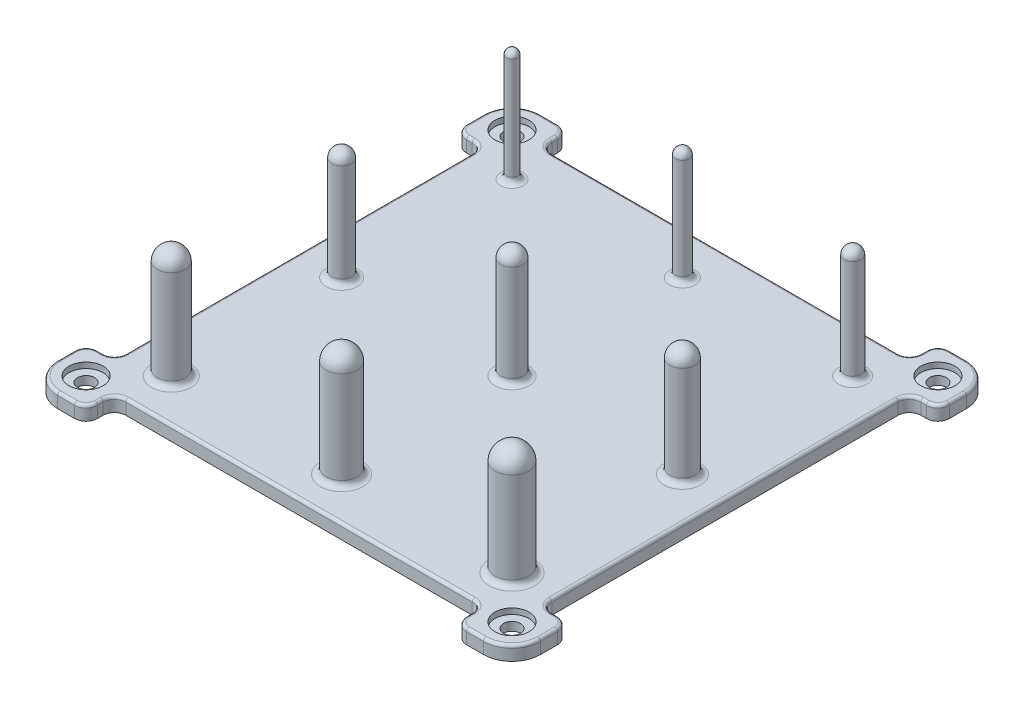
from build123d import *

# Parameters (mm, degrees)
BOSS_EXTRUDE1_DEPTH = 5
SKETCH3_R           = 6
CUT_EXTRUDE1_DEPTH  = 2
SKETCH9_R           = 3
CUT_EXTRUDE4_DEPTH  = 6
SKETCH10_R          = 2
SKETCH10_R_2        = 2.5
SKETCH10_R_3        = 3
SKETCH10_R_4        = 3.5
SKETCH10_R_5        = 4
SKETCH10_R_6        = 4.5
SKETCH10_R_7        = 5
SKETCH10_R_8        = 5.5
SKETCH10_R_9        = 6
BOSS_EXTRUDE6_DEPTH = 40
FILLET1_R           = 2
FILLET2_R           = 2.5
FILLET3_R           = 3
FILLET4_R           = 3.5
FILLET5_R           = 4
FILLET6_R           = 4.5
FILLET7_R           = 5
FILLET8_R           = 5.5
FILLET9_R           = 6
FILLET11_R          = 2
FILLET12_R          = 2
FILLET13_R          = 2
FILLET14_R          = 2
FILLET15_R          = 2
FILLET16_R          = 2
FILLET17_R          = 2
FILLET18_R          = 2
FILLET19_R          = 2
SKETCH12_OUTSIDE_W  = 220.918
SKETCH12_OUTSIDE_H  = 220.918
CUT_EXTRUDE5_DEPTH  = 40
FILLET20_R          = 1


with BuildPart() as part:
    # Sketch2 → Boss-Extrude1 (new body)
    with BuildSketch(Plane(origin=(0, 0, 0), x_dir=(1, 0, 0), z_dir=(0, 1, 0))):
        with BuildLine():
            Line((-78.251928021, 33.643958869), (71.748071979, 33.643958869))
            ThreePointArc((71.748071979, 33.643958869), (78.819139791, 30.715026681), (81.748071979, 23.643958869))
            Line((81.748071979, 23.643958869), (81.748071979, -126.356041131))
            ThreePointArc((81.748071979, -126.356041131), (78.819139791, -133.427108943), (71.748071979, -136.356041131))
            Line((71.748071979, -136.356041131), (-78.251928021, -136.356041131))
            ThreePointArc((-78.251928021, -136.356041131), (-85.322995832, -133.427108943), (-88.251928021, -126.356041131))
            Line((-88.251928021, -126.356041131), (-88.251928021, 23.643958869))
            ThreePointArc((-88.251928021, 23.643958869), (-85.322995832, 30.715026681), (-78.251928021, 33.643958869))
        make_face()
    extrude(amount=BOSS_EXTRUDE1_DEPTH)

    # Sketch3 → Cut-Extrude1 (cut)
    with BuildSketch(Plane(origin=(0, 5, 0), x_dir=(1, 0, 0), z_dir=(0, 1, 0))):
        with Locations((71.748071979, 23.643958869)):
            Circle(SKETCH3_R)
        with Locations((71.748071979, -126.356041131)):
            Circle(SKETCH3_R)
        with Locations((-78.251928021, 23.643958869)):
            Circle(SKETCH3_R)
        with Locations((-78.251928021, -126.356041131)):
            Circle(SKETCH3_R)
    extrude(amount=-CUT_EXTRUDE1_DEPTH, mode=Mode.SUBTRACT)

    # Sketch9 → Cut-Extrude4 (cut, through all)
    with BuildSketch(Plane(origin=(0, 5, 0), x_dir=(1, 0, 0), z_dir=(0, 1, 0))):
        with Locations((-78.251928021, 23.643958869)):
            Circle(SKETCH9_R)
        with Locations((71.748071979, 23.643958869)):
            Circle(SKETCH9_R)
        with Locations((71.748071979, -126.356041131)):
            Circle(SKETCH9_R)
        with Locations((-78.251928021, -126.356041131)):
            Circle(SKETCH9_R)
    extrude(amount=-CUT_EXTRUDE4_DEPTH, mode=Mode.SUBTRACT)

    # Sketch10 → Boss-Extrude6 (add)
    with BuildSketch(Plane(origin=(0, 5, 0), x_dir=(1, 0, 0), z_dir=(0, 1, 0))):
        with Locations((-63.251928021, 8.643958869)):
            Circle(SKETCH10_R)
        with Locations((-3.251928021, 8.643958869)):
            Circle(SKETCH10_R_2)
        with Locations((56.748071979, 8.643958869)):
            Circle(SKETCH10_R_3)
        with Locations((-63.251928021, -51.356041131)):
            Circle(SKETCH10_R_4)
        with Locations((-3.251928021, -51.356041131)):
            Circle(SKETCH10_R_5)
        with Locations((56.748071979, -51.356041131)):
            Circle(SKETCH10_R_6)
        with Locations((-63.251928021, -111.356041131)):
            Circle(SKETCH10_R_7)
        with Locations((-3.251928021, -111.356041131)):
            Circle(SKETCH10_R_8)
        with Locations((56.748071979, -111.356041131)):
            Circle(SKETCH10_R_9)
    extrude(amount=BOSS_EXTRUDE6_DEPTH)

    # Fillet1
    fillet1_edges = [part.edges().sort_by_distance(p)[0] for p in [
        (-65.251928021, 45, -8.643958869),
    ]]
    fillet(fillet1_edges, radius=FILLET1_R)

    # Fillet2
    fillet2_edges = [part.edges().sort_by_distance(p)[0] for p in [
        (-5.751928021, 45, -8.643958869),
    ]]
    fillet(fillet2_edges, radius=FILLET2_R)

    # Fillet3
    fillet3_edges = [part.edges().sort_by_distance(p)[0] for p in [
        (53.748071979, 45, -8.643958869),
    ]]
    fillet(fillet3_edges, radius=FILLET3_R)

    # Fillet4
    fillet4_edges = [part.edges().sort_by_distance(p)[0] for p in [
        (-66.751928021, 45, 51.356041131),
    ]]
    fillet(fillet4_edges, radius=FILLET4_R)

    # Fillet5
    fillet5_edges = [part.edges().sort_by_distance(p)[0] for p in [
        (-7.251928021, 45, 51.356041131),
    ]]
    fillet(fillet5_edges, radius=FILLET5_R)

    # Fillet6
    fillet6_edges = [part.edges().sort_by_distance(p)[0] for p in [
        (52.248071979, 45, 51.356041131),
    ]]
    fillet(fillet6_edges, radius=FILLET6_R)

    # Fillet7
    fillet7_edges = [part.edges().sort_by_distance(p)[0] for p in [
        (-68.251928021, 45, 111.356041131),
    ]]
    fillet(fillet7_edges, radius=FILLET7_R)

    # Fillet8
    fillet8_edges = [part.edges().sort_by_distance(p)[0] for p in [
        (-8.751928021, 45, 111.356041131),
    ]]
    fillet(fillet8_edges, radius=FILLET8_R)

    # Fillet9
    fillet9_edges = [part.edges().sort_by_distance(p)[0] for p in [
        (50.748071979, 45, 111.356041131),
    ]]
    fillet(fillet9_edges, radius=FILLET9_R)

    # Fillet11
    fillet11_edges = [part.edges().sort_by_distance(p)[0] for p in [
        (-65.251928021, 5, -8.643958869),
    ]]
    fillet(fillet11_edges, radius=FILLET11_R)

    # Fillet12
    fillet12_edges = [part.edges().sort_by_distance(p)[0] for p in [
        (-5.751928021, 5, -8.643958869),
    ]]
    fillet(fillet12_edges, radius=FILLET12_R)

    # Fillet13
    fillet13_edges = [part.edges().sort_by_distance(p)[0] for p in [
        (53.748071979, 5, -8.643958869),
    ]]
    fillet(fillet13_edges, radius=FILLET13_R)

    # Fillet14
    fillet14_edges = [part.edges().sort_by_distance(p)[0] for p in [
        (-66.751928021, 5, 51.356041131),
    ]]
    fillet(fillet14_edges, radius=FILLET14_R)

    # Fillet15
    fillet15_edges = [part.edges().sort_by_distance(p)[0] for p in [
        (-7.251928021, 5, 51.356041131),
    ]]
    fillet(fillet15_edges, radius=FILLET15_R)

    # Fillet16
    fillet16_edges = [part.edges().sort_by_distance(p)[0] for p in [
        (52.248071979, 5, 51.356041131),
    ]]
    fillet(fillet16_edges, radius=FILLET16_R)

    # Fillet17
    fillet17_edges = [part.edges().sort_by_distance(p)[0] for p in [
        (-68.251928021, 5, 111.356041131),
    ]]
    fillet(fillet17_edges, radius=FILLET17_R)

    # Fillet18
    fillet18_edges = [part.edges().sort_by_distance(p)[0] for p in [
        (-8.751928021, 5, 111.356041131),
    ]]
    fillet(fillet18_edges, radius=FILLET18_R)

    # Fillet19
    fillet19_edges = [part.edges().sort_by_distance(p)[0] for p in [
        (50.748071979, 5, 111.356041131),
    ]]
    fillet(fillet19_edges, radius=FILLET19_R)

    # Sketch12 outside → Cut-Extrude5 (cut)
    with BuildSketch(Plane(origin=(0, 5, 0), x_dir=(1, 0, 0), z_dir=(0, 1, 0))):
        with Locations((-3.252, -51.356)):
            Rectangle(SKETCH12_OUTSIDE_W, SKETCH12_OUTSIDE_H)
        with BuildLine():
            Line((-64.251928021, 23.643958869), (57.748071979, 23.643958869))
            ThreePointArc((57.748071979, 23.643958869), (60.576499104, 24.815531744), (61.748071979, 27.643958869))
            Line((61.748071979, 27.643958869), (61.748071979, 29.643958869))
            ThreePointArc((61.748071979, 29.643958869), (62.919644855, 32.472385994), (65.748071979, 33.643958869))
            Line((65.748071979, 33.643958869), (71.748071979, 33.643958869))
            Line((71.748071979, 33.643958869), (81.749247741, 33.643958869))
            Line((81.749247741, 33.643958869), (81.748071979, 23.643958869))
            Line((81.748071979, 23.643958869), (81.748071979, 17.643958869))
            ThreePointArc((81.748071979, 17.643958869), (80.576499104, 14.815531744), (77.748071979, 13.643958869))
            Line((77.748071979, 13.643958869), (75.748071979, 13.643958869))
            ThreePointArc((75.748071979, 13.643958869), (72.919644855, 12.472385994), (71.748071979, 9.643958869))
            Line((71.748071979, 9.643958869), (71.748071979, -112.356041131))
            ThreePointArc((71.748071979, -112.356041131), (72.919644855, -115.184468256), (75.748071979, -116.356041131))
            Line((75.748071979, -116.356041131), (77.748071979, -116.356041131))
            ThreePointArc((77.748071979, -116.356041131), (80.576499104, -117.527614006), (81.748071979, -120.356041131))
            Line((81.748071979, -120.356041131), (81.748071979, -126.356041131))
            Line((81.748071979, -126.356041131), (81.748071979, -136.356041131))
            Line((81.748071979, -136.356041131), (71.748071979, -136.356041131))
            Line((71.748071979, -136.356041131), (65.748071979, -136.356041131))
            ThreePointArc((65.748071979, -136.356041131), (62.919644855, -135.184468256), (61.748071979, -132.356041131))
            Line((61.748071979, -132.356041131), (61.748071979, -130.356041131))
            ThreePointArc((61.748071979, -130.356041131), (60.576499104, -127.527614006), (57.748071979, -126.356041131))
            Line((57.748071979, -126.356041131), (-64.251928021, -126.356041131))
            ThreePointArc((-64.251928021, -126.356041131), (-67.080355145, -127.527614006), (-68.251928021, -130.356041131))
            Line((-68.251928021, -130.356041131), (-68.251928021, -132.356041131))
            ThreePointArc((-68.251928021, -132.356041131), (-69.423500896, -135.184468256), (-72.251928021, -136.356041131))
            Line((-72.251928021, -136.356041131), (-78.251928021, -136.356041131))
            Line((-78.251928021, -136.356041131), (-88.251928021, -136.356041131))
            Line((-88.251928021, -136.356041131), (-88.251928021, -126.356041131))
            Line((-88.251928021, -126.356041131), (-88.251928021, -120.356041131))
            ThreePointArc((-88.251928021, -120.356041131), (-87.080355145, -117.527614006), (-84.251928021, -116.356041131))
            Line((-84.251928021, -116.356041131), (-82.251928021, -116.356041131))
            ThreePointArc((-82.251928021, -116.356041131), (-79.423500896, -115.184468256), (-78.251928021, -112.356041131))
            Line((-78.251928021, -112.356041131), (-78.251928021, 9.643958869))
            ThreePointArc((-78.251928021, 9.643958869), (-79.423500896, 12.472385994), (-82.251928021, 13.643958869))
            Line((-82.251928021, 13.643958869), (-84.251928021, 13.643958869))
            ThreePointArc((-84.251928021, 13.643958869), (-87.080355145, 14.815531744), (-88.251928021, 17.643958869))
            Line((-88.251928021, 17.643958869), (-88.251928021, 23.643958869))
            Line((-88.251928021, 23.643958869), (-88.251928021, 33.643958869))
            Line((-88.251928021, 33.643958869), (-78.251928021, 33.643958869))
            Line((-78.251928021, 33.643958869), (-72.251928021, 33.643958869))
            ThreePointArc((-72.251928021, 33.643958869), (-69.423500896, 32.472385994), (-68.251928021, 29.643958869))
            Line((-68.251928021, 29.643958869), (-68.251928021, 27.643958869))
            ThreePointArc((-68.251928021, 27.643958869), (-67.080355145, 24.815531744), (-64.251928021, 23.643958869))
        make_face(mode=Mode.SUBTRACT)
    extrude(amount=-CUT_EXTRUDE5_DEPTH, mode=Mode.SUBTRACT)

    # Fillet20
    fillet20_edges = [part.edges().sort_by_distance(p)[0] for p in [
        (78.819139791, 5, 133.427108943),
        (68.748071979, 5, 136.356041131),
        (81.748071979, 5, -20.643958869),
        (-75.251928021, 5, -33.643958869),
        (-88.251928021, 5, 123.356041131),
        (81.748071979, 5, 123.356041131),
        (-69.423500896, 5, -32.472385994),
        (-68.251928021, 5, -28.643958869),
        (-67.080355145, 5, -24.815531744),
        (-3.251928021, 5, -23.643958869),
        (60.576499104, 5, -24.815531744),
        (61.748071979, 5, -28.643958869),
        (62.919644855, 5, -32.472385994),
        (80.576499104, 5, -14.815531744),
        (76.748071979, 5, -13.643958869),
        (72.919644855, 5, -12.472385994),
        (71.748071979, 5, 51.356041131),
        (72.919644855, 5, 115.184468256),
        (76.748071979, 5, 116.356041131),
        (80.576499104, 5, 117.527614006),
        (62.919644855, 5, 135.184468256),
        (61.748071979, 5, 131.356041131),
        (60.576499104, 5, 127.527614006),
        (-3.251928021, 5, 126.356041131),
        (-67.080355145, 5, 127.527614006),
        (-68.251928021, 5, 131.356041131),
        (-69.423500896, 5, 135.184468256),
        (-87.080355145, 5, 117.527614006),
        (-83.251928021, 5, 116.356041131),
        (-79.423500896, 5, 115.184468256),
        (-78.251928021, 5, 51.356041131),
        (-79.423500896, 5, -12.472385994),
        (-83.251928021, 5, -13.643958869),
        (-87.080355145, 5, -14.815531744),
        (78.819139791, 5, -30.715026681),
        (68.748071979, 5, -33.643958869),
        (-85.322995832, 5, -30.715026681),
        (-88.251928021, 5, -20.643958869),
        (-85.322995832, 5, 133.427108943),
        (-75.251928021, 5, 136.356041131),
    ]]
    fillet(fillet20_edges, radius=FILLET20_R)


solid = part.part
